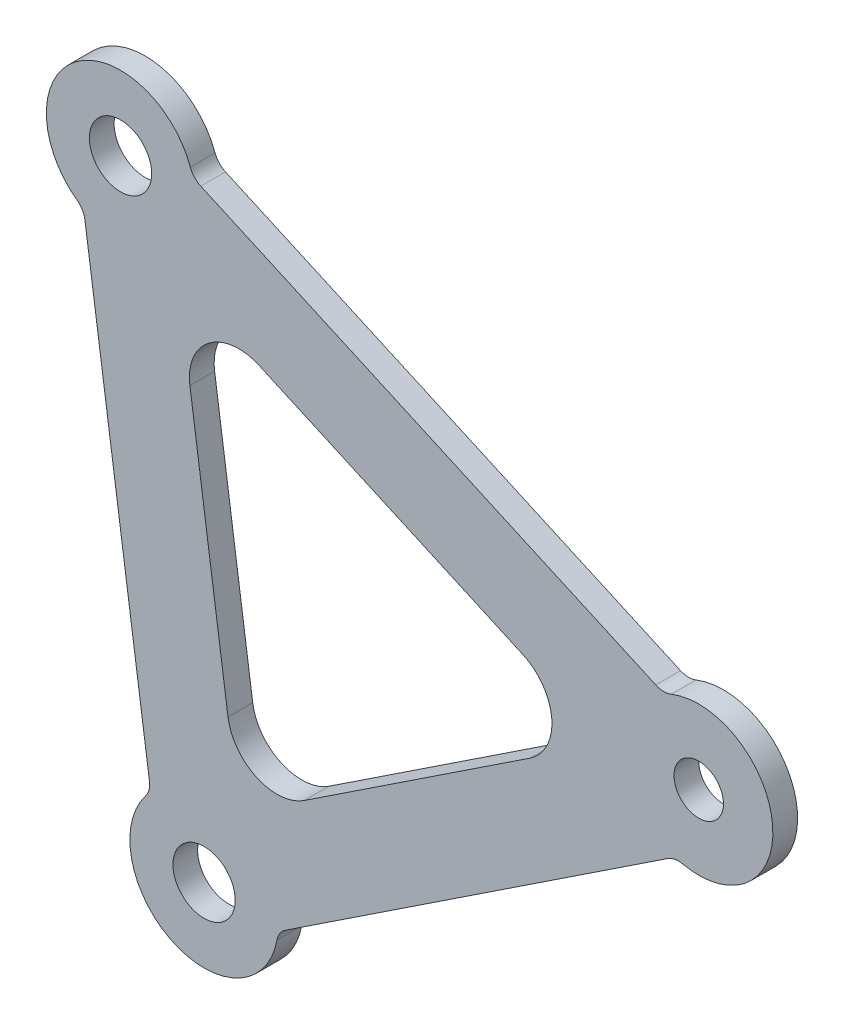
from build123d import *

# Parameters (mm, degrees)
BOSS_EXTRUDE1_DEPTH  = 3.175
SKETCH1_4_R          = 4
SKETCH1_4_R_2        = 3.175
HOLES_DEPTH          = 3.175
SKETCH5_OUTSIDE_W    = 151.471
SKETCH5_OUTSIDE_H    = 153.323
OUTSIDEEXTRUDE_DEPTH = 3.81
INNERTRIANGLE_DEPTH  = 3.81
FILLET2_R            = 6.35
FILLET3_R            = 2.54


with BuildPart() as part:
    # Sketch1 → Boss-Extrude1 (new body)
    with BuildSketch(Plane.XY.offset(1577.629912845)):
        Polygon((200.232199361, 713.672399287), (217.036775663, 595.514826781), (316.536854979, 661.418847479), align=None)
    extrude(amount=BOSS_EXTRUDE1_DEPTH)

    # Sketch1_4 → Holes (cut)
    with BuildSketch(Plane.XY.offset(1577.629912845)):
        with Locations((216.050914922, 692.642443937)):
            Circle(SKETCH1_4_R)
        with Locations((290.308718483, 659.279772728)):
            Circle(SKETCH1_4_R_2)
        with Locations((226.780244033, 617.20159627)):
            Circle(SKETCH1_4_R)
    extrude(amount=HOLES_DEPTH, mode=Mode.SUBTRACT)

    # Sketch5 outside → OutsideExtrude (cut)
    with BuildSketch(Plane(origin=(0, 0, 1577.629912845), x_dir=(-1, 0, 0), z_dir=(0, 0, -1))):
        with Locations((-258.3845, 654.5935)):
            Rectangle(SKETCH5_OUTSIDE_W, SKETCH5_OUTSIDE_H)
        with BuildLine():
            Line((-211.315771723, 684.377817887), (-219.928647009, 623.818335891))
            ThreePointArc((-219.928647009, 623.818335891), (-222.876711188, 608.51320998), (-236.277349403, 616.473163308))
            Line((-236.277349403, 616.473163308), (-287.274277772, 650.251052189))
            ThreePointArc((-287.274277772, 650.251052189), (-299.802198055, 660.0540276), (-285.851407356, 667.697492284))
            Line((-285.851407356, 667.697492284), (-225.304484054, 694.900116089))
            ThreePointArc((-225.304484054, 694.900116089), (-210.325206852, 700.25440111), (-211.315771723, 684.377817887))
        make_face(mode=Mode.SUBTRACT)
    extrude(amount=-OUTSIDEEXTRUDE_DEPTH, mode=Mode.SUBTRACT)

    # Sketch6 → InnerTriangle (cut)
    with BuildSketch(Plane(origin=(0, 0, 1577.629912845), x_dir=(-1, 0, 0), z_dir=(0, 0, -1))):
        Polygon((-223.339566396, 682.952655016), (-231.269656883, 627.194019699), (-278.223809028, 658.294169931), align=None)
    extrude(amount=-INNERTRIANGLE_DEPTH, mode=Mode.SUBTRACT)

    # Fillet2
    fillet2_edges = [part.edges().sort_by_distance(p)[0] for p in [
        (278.223809028, 658.294169931, 1579.217412845),
        (231.269656883, 627.194019699, 1579.217412845),
        (223.339566396, 682.952655016, 1579.217412845),
    ]]
    fillet(fillet2_edges, radius=FILLET2_R)

    # Fillet3
    fillet3_edges = [part.edges().sort_by_distance(p)[0] for p in [
        (285.851407356, 667.697492284, 1579.217412845),
        (287.274277772, 650.251052189, 1579.217412845),
        (236.277349403, 616.473163308, 1579.217412845),
        (219.928647009, 623.818335891, 1579.217412845),
        (211.315771723, 684.377817887, 1579.217412845),
        (225.304484054, 694.900116089, 1579.217412845),
    ]]
    fillet(fillet3_edges, radius=FILLET3_R)


solid = part.part
